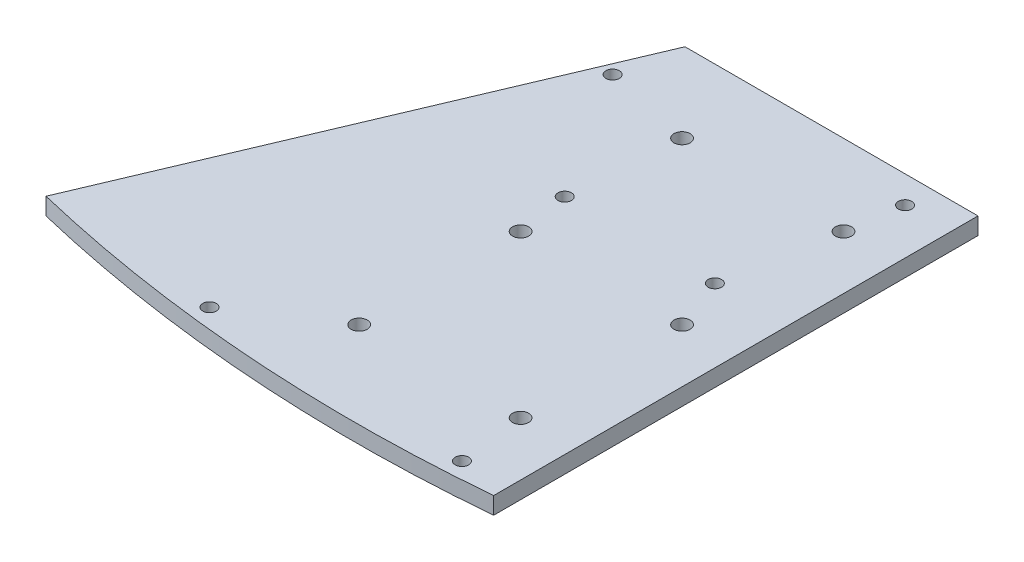
from build123d import *

# Parameters (mm, degrees)
SKETCH1_R           = 1.5
SKETCH1_R_2         = 1.25
BOSS_EXTRUDE1_DEPTH = 3.175


with BuildPart() as part:
    # Sketch1 → Boss-Extrude1 (new body)
    with BuildSketch(Plane(origin=(0, 0, 0), x_dir=(1, 0, 0), z_dir=(0, 1, 0))):
        with BuildLine():
            Line((-44.45, 75), (10, 75))
            Line((10, 75), (10, -15))
            ThreePointArc((10, -15), (-35.153948529, -15.397564184), (-79.768950839, -8.430592532))
            Line((-79.768950839, -8.430592532), (-44.45, 75))
        make_face()
        Circle(SKETCH1_R, mode=Mode.SUBTRACT)
        with Locations((-30, 0)):
            Circle(SKETCH1_R, mode=Mode.SUBTRACT)
        with Locations((-30, 30)):
            Circle(SKETCH1_R, mode=Mode.SUBTRACT)
        with Locations((-30, 60)):
            Circle(SKETCH1_R, mode=Mode.SUBTRACT)
        with Locations((0, 60)):
            Circle(SKETCH1_R, mode=Mode.SUBTRACT)
        with Locations((0, 30)):
            Circle(SKETCH1_R, mode=Mode.SUBTRACT)
        with Locations((-46.7, 63.8)):
            Circle(SKETCH1_R_2, mode=Mode.SUBTRACT)
        with Locations((1.5, 69.95)):
            Circle(SKETCH1_R_2, mode=Mode.SUBTRACT)
        with Locations((-31.5, 39.7)):
            Circle(SKETCH1_R_2, mode=Mode.SUBTRACT)
        with Locations((-3.6, 39.7)):
            Circle(SKETCH1_R_2, mode=Mode.SUBTRACT)
        with Locations((-46.7, -11.1)):
            Circle(SKETCH1_R_2, mode=Mode.SUBTRACT)
        with Locations((1.5, -12.4)):
            Circle(SKETCH1_R_2, mode=Mode.SUBTRACT)
    extrude(amount=BOSS_EXTRUDE1_DEPTH)


solid = part.part
